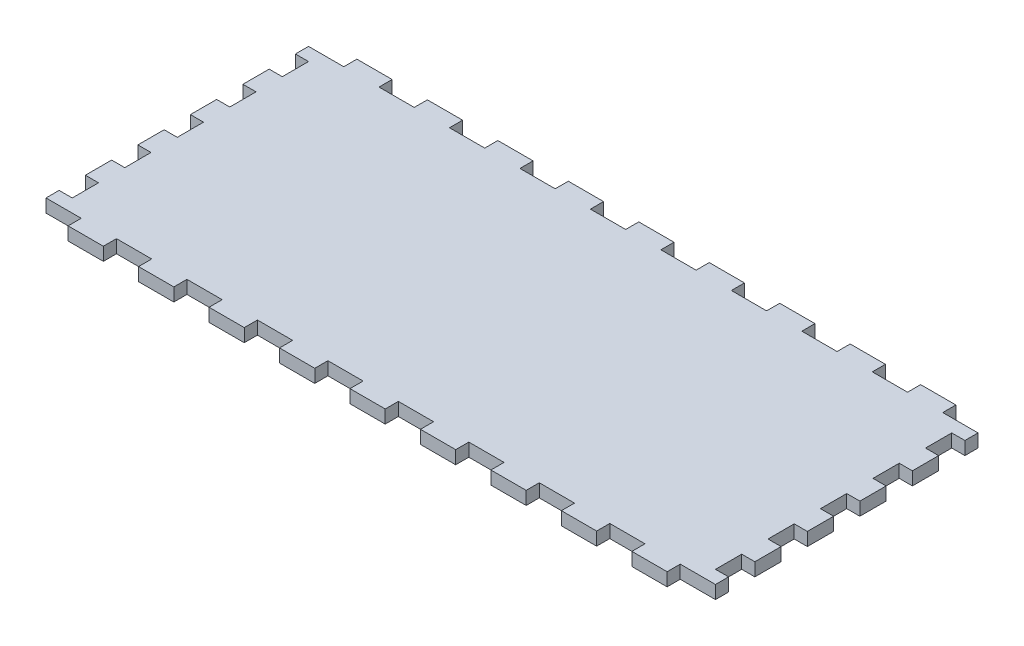
from build123d import *

# Parameters (mm, degrees)
SKETCH1_W              = 323.85
SKETCH1_H              = 139.7
BOSS_EXTRUDE1_DEPTH    = 6.35
SKETCH2_W              = 323.85
SKETCH2_H              = 139.7
SKETCH2_W_2            = 311.15
SKETCH2_H_2            = 127
BOSS_EXTRUDE2_DEPTH    = 298.45
SKETCH3_W              = 6.35
SKETCH3_H              = 16.933333333
SKETCH3_H_2            = 16.933333334
DOOR_SLOT_DEPTH        = 12.7
SKETCH4_W              = 6.35
SKETCH4_H              = 15.875
DOOR_GUIDE_HOLES_DEPTH = 6.35
LEVER_HOLES_W          = 9.652
LEVER_HOLES_H          = 6.35
LEVER_HOLES_W_2        = 6.35
CUT_EXTRUDE1_DEPTH     = 140.7
CUT_EXTRUDE2_REACH     = 325.85
SKETCH7_R              = 26.9875
CUT_EXTRUDE3_REACH     = 325.85
SKETCH8_R              = 3.175
SKETCH9_W              = 323.85
SKETCH9_H              = 298.45
CUT_EXTRUDE4_DEPTH     = 140.7
SKETCH10_W             = 10.694736842
SKETCH10_H             = 6.35
SKETCH10_W_2           = 6.35
SKETCH10_W_3           = 17.044736842
SKETCH10_W_4           = 17.044736843
SKETCH10_H_2           = 12.7
CUT_EXTRUDE6_DEPTH     = 7.35


with BuildPart() as part:
    # Sketch1 → Boss-Extrude1 (new body)
    with BuildSketch(Plane(origin=(0, 0, 0), x_dir=(1, 0, 0), z_dir=(0, 1, 0))):
        Rectangle(SKETCH1_W, SKETCH1_H)
    extrude(amount=BOSS_EXTRUDE1_DEPTH)

    # Sketch2 → Boss-Extrude2 (add)
    with BuildSketch(Plane(origin=(0, 6.35, 0), x_dir=(1, 0, 0), z_dir=(0, 1, 0))):
        Rectangle(SKETCH2_W, SKETCH2_H)
        Rectangle(SKETCH2_W_2, SKETCH2_H_2, mode=Mode.SUBTRACT)
    extrude(amount=BOSS_EXTRUDE2_DEPTH)

    # Sketch3 → Door Slot (cut)
    with BuildSketch(Plane.XY.offset(69.85)):
        with BuildLine():
            Line((-53.975, 283.21), (-53.975, 6.35))
            Line((-53.975, 6.35), (-47.371, 6.35))
            Line((-47.371, 6.35), (-47.371, 292.354))
            Line((-47.371, 292.354), (-66.929, 292.354))
            Line((-66.929, 292.354), (-66.929, 285.75))
            Line((-66.929, 285.75), (-56.515, 285.75))
            ThreePointArc((-56.515, 285.75), (-54.718948776, 285.006051224), (-53.975, 283.21))
        make_face()
        with Locations((-37.846, 80.433333334)):
            Rectangle(SKETCH3_W, SKETCH3_H)
        with Locations((-37.846, 50.8)):
            Rectangle(SKETCH3_W, SKETCH3_H_2)
        with Locations((-37.846, 21.166666667)):
            Rectangle(SKETCH3_W, SKETCH3_H)
    extrude(amount=-DOOR_SLOT_DEPTH, mode=Mode.SUBTRACT)

    # Sketch4 → Door Guide Holes (cut)
    with BuildSketch(Plane.XY.offset(-63.5)):
        with Locations((-70.104, 284.1625)):
            Rectangle(SKETCH4_W, SKETCH4_H)
        with Locations((-70.104, 255.5875)):
            Rectangle(SKETCH4_W, SKETCH4_H)
        with Locations((-70.104, 227.0125)):
            Rectangle(SKETCH4_W, SKETCH4_H)
        with Locations((-70.104, 198.4375)):
            Rectangle(SKETCH4_W, SKETCH4_H)
        with Locations((-70.104, 169.8625)):
            Rectangle(SKETCH4_W, SKETCH4_H)
        with Locations((-70.104, 141.2875)):
            Rectangle(SKETCH4_W, SKETCH4_H)
        with Locations((-70.104, 112.7125)):
            Rectangle(SKETCH4_W, SKETCH4_H)
        with Locations((-70.104, 84.1375)):
            Rectangle(SKETCH4_W, SKETCH4_H)
        with Locations((-70.104, 55.5625)):
            Rectangle(SKETCH4_W, SKETCH4_H)
        with Locations((-70.104, 26.9875)):
            Rectangle(SKETCH4_W, SKETCH4_H)
    door_guide_holes = extrude(amount=-DOOR_GUIDE_HOLES_DEPTH, mode=Mode.SUBTRACT)

    # Mirror1: Door Guide Holes across plane
    add(door_guide_holes.mirror(Plane.ZY.offset(57.15)), mode=Mode.SUBTRACT)

    # Lever Holes → Cut-Extrude1 (cut, through all)
    with BuildSketch(Plane.XY.offset(69.85)):
        with Locations((54.102, 28.575)):
            Rectangle(LEVER_HOLES_W, LEVER_HOLES_H)
        with Locations((39.3065, 15.875)):
            Rectangle(LEVER_HOLES_W_2, LEVER_HOLES_H)
        with Locations((68.8975, 15.875)):
            Rectangle(LEVER_HOLES_W_2, LEVER_HOLES_H)
    extrude(amount=-CUT_EXTRUDE1_DEPTH, mode=Mode.SUBTRACT)

    # Sketch7 → Cut-Extrude2 (cut, up to next)
    with BuildSketch(Plane(origin=(161.925, 0, 0), x_dir=(0, 0, -1), z_dir=(1, 0, 0)), mode=Mode.PRIVATE) as cut_extrude2_sk1:
        with Locations((0, 55.372)):
            Circle(SKETCH7_R)
    cut_extrude2_tool1 = extrude(cut_extrude2_sk1.sketch, amount=-CUT_EXTRUDE2_REACH, mode=Mode.PRIVATE) & part.part
    add(cut_extrude2_tool1.solids().sort_by_distance((161.925, 55.372, 0))[0], mode=Mode.SUBTRACT)
    # Sketch7 → Cut-Extrude2 (cut, up to next)
    with BuildSketch(Plane(origin=(161.925, 0, 0), x_dir=(0, 0, -1), z_dir=(1, 0, 0)), mode=Mode.PRIVATE) as cut_extrude2_sk2:
        with BuildLine():
            Line((-37.211, 89.408), (-37.211, 92.583))
            Line((-37.211, 92.583), (-34.036, 92.583))
            ThreePointArc((-34.036, 92.583), (-39.45606403, 94.82806403), (-37.211, 89.408))
        make_face()
    cut_extrude2_tool2 = extrude(cut_extrude2_sk2.sketch, amount=-CUT_EXTRUDE2_REACH, mode=Mode.PRIVATE) & part.part
    add(cut_extrude2_tool2.solids().sort_by_distance((161.925, 93.032171, 37.660171))[0], mode=Mode.SUBTRACT)
    # Sketch7 → Cut-Extrude2 (cut, up to next)
    with BuildSketch(Plane(origin=(161.925, 0, 0), x_dir=(0, 0, -1), z_dir=(1, 0, 0)), mode=Mode.PRIVATE) as cut_extrude2_sk3:
        with BuildLine():
            Line((-34.036, 92.583), (-37.211, 92.583))
            Line((-37.211, 92.583), (-37.211, 89.408))
            ThreePointArc((-37.211, 89.408), (-34.96593597, 90.33793597), (-34.036, 92.583))
        make_face()
    cut_extrude2_tool3 = extrude(cut_extrude2_sk3.sketch, amount=-CUT_EXTRUDE2_REACH, mode=Mode.PRIVATE) & part.part
    add(cut_extrude2_tool3.solids().sort_by_distance((161.925, 91.235488, 35.863488))[0], mode=Mode.SUBTRACT)
    # Sketch7 → Cut-Extrude2 (cut, up to next)
    with BuildSketch(Plane(origin=(161.925, 0, 0), x_dir=(0, 0, -1), z_dir=(1, 0, 0)), mode=Mode.PRIVATE) as cut_extrude2_sk4:
        with BuildLine():
            Line((-37.211, 89.408), (-37.211, 92.583))
            Line((-37.211, 92.583), (-34.036, 92.583))
            ThreePointArc((-34.036, 92.583), (-39.45606403, 94.82806403), (-37.211, 89.408))
        make_face()
    cut_extrude2_tool4 = extrude(cut_extrude2_sk4.sketch, amount=-CUT_EXTRUDE2_REACH, mode=Mode.PRIVATE) & part.part
    add(cut_extrude2_tool4.solids().sort_by_distance((161.925, 93.032171, 37.660171))[0], mode=Mode.SUBTRACT)
    # Sketch7 → Cut-Extrude2 (cut, up to next)
    with BuildSketch(Plane(origin=(161.925, 0, 0), x_dir=(0, 0, -1), z_dir=(1, 0, 0)), mode=Mode.PRIVATE) as cut_extrude2_sk5:
        with BuildLine():
            Line((-34.036, 92.583), (-37.211, 92.583))
            Line((-37.211, 92.583), (-37.211, 89.408))
            ThreePointArc((-37.211, 89.408), (-34.96593597, 90.33793597), (-34.036, 92.583))
        make_face()
    cut_extrude2_tool5 = extrude(cut_extrude2_sk5.sketch, amount=-CUT_EXTRUDE2_REACH, mode=Mode.PRIVATE) & part.part
    add(cut_extrude2_tool5.solids().sort_by_distance((161.925, 91.235488, 35.863488))[0], mode=Mode.SUBTRACT)
    # Sketch7 → Cut-Extrude2 (cut, up to next)
    with BuildSketch(Plane(origin=(161.925, 0, 0), x_dir=(0, 0, -1), z_dir=(1, 0, 0)), mode=Mode.PRIVATE) as cut_extrude2_sk6:
        with BuildLine():
            ThreePointArc((40.386, 92.583), (37.211, 95.758), (34.036, 92.583))
            Line((34.036, 92.583), (37.211, 92.583))
            Line((37.211, 92.583), (37.211, 89.408))
            ThreePointArc((37.211, 89.408), (39.45606403, 90.33793597), (40.386, 92.583))
        make_face()
    cut_extrude2_tool6 = extrude(cut_extrude2_sk6.sketch, amount=-CUT_EXTRUDE2_REACH, mode=Mode.PRIVATE) & part.part
    add(cut_extrude2_tool6.solids().sort_by_distance((161.925, 93.032171, -37.660171))[0], mode=Mode.SUBTRACT)
    # Sketch7 → Cut-Extrude2 (cut, up to next)
    with BuildSketch(Plane(origin=(161.925, 0, 0), x_dir=(0, 0, -1), z_dir=(1, 0, 0)), mode=Mode.PRIVATE) as cut_extrude2_sk7:
        with BuildLine():
            Line((37.211, 92.583), (34.036, 92.583))
            ThreePointArc((34.036, 92.583), (34.96593597, 90.33793597), (37.211, 89.408))
            Line((37.211, 89.408), (37.211, 92.583))
        make_face()
    cut_extrude2_tool7 = extrude(cut_extrude2_sk7.sketch, amount=-CUT_EXTRUDE2_REACH, mode=Mode.PRIVATE) & part.part
    add(cut_extrude2_tool7.solids().sort_by_distance((161.925, 91.235488, -35.863488))[0], mode=Mode.SUBTRACT)
    # Sketch7 → Cut-Extrude2 (cut, up to next)
    with BuildSketch(Plane(origin=(161.925, 0, 0), x_dir=(0, 0, -1), z_dir=(1, 0, 0)), mode=Mode.PRIVATE) as cut_extrude2_sk8:
        with BuildLine():
            ThreePointArc((40.386, 92.583), (37.211, 95.758), (34.036, 92.583))
            Line((34.036, 92.583), (37.211, 92.583))
            Line((37.211, 92.583), (37.211, 89.408))
            ThreePointArc((37.211, 89.408), (39.45606403, 90.33793597), (40.386, 92.583))
        make_face()
    cut_extrude2_tool8 = extrude(cut_extrude2_sk8.sketch, amount=-CUT_EXTRUDE2_REACH, mode=Mode.PRIVATE) & part.part
    add(cut_extrude2_tool8.solids().sort_by_distance((161.925, 93.032171, -37.660171))[0], mode=Mode.SUBTRACT)
    # Sketch7 → Cut-Extrude2 (cut, up to next)
    with BuildSketch(Plane(origin=(161.925, 0, 0), x_dir=(0, 0, -1), z_dir=(1, 0, 0)), mode=Mode.PRIVATE) as cut_extrude2_sk9:
        with BuildLine():
            Line((37.211, 92.583), (34.036, 92.583))
            ThreePointArc((34.036, 92.583), (34.96593597, 90.33793597), (37.211, 89.408))
            Line((37.211, 89.408), (37.211, 92.583))
        make_face()
    cut_extrude2_tool9 = extrude(cut_extrude2_sk9.sketch, amount=-CUT_EXTRUDE2_REACH, mode=Mode.PRIVATE) & part.part
    add(cut_extrude2_tool9.solids().sort_by_distance((161.925, 91.235488, -35.863488))[0], mode=Mode.SUBTRACT)
    # Sketch7 → Cut-Extrude2 (cut, up to next)
    with BuildSketch(Plane(origin=(161.925, 0, 0), x_dir=(0, 0, -1), z_dir=(1, 0, 0)), mode=Mode.PRIVATE) as cut_extrude2_sk10:
        with BuildLine():
            ThreePointArc((-34.036, 18.161), (-34.96593597, 20.40606403), (-37.211, 21.336))
            Line((-37.211, 21.336), (-37.211, 18.161))
            Line((-37.211, 18.161), (-34.036, 18.161))
        make_face()
    cut_extrude2_tool10 = extrude(cut_extrude2_sk10.sketch, amount=-CUT_EXTRUDE2_REACH, mode=Mode.PRIVATE) & part.part
    add(cut_extrude2_tool10.solids().sort_by_distance((161.925, 19.508512, 35.863488))[0], mode=Mode.SUBTRACT)
    # Sketch7 → Cut-Extrude2 (cut, up to next)
    with BuildSketch(Plane(origin=(161.925, 0, 0), x_dir=(0, 0, -1), z_dir=(1, 0, 0)), mode=Mode.PRIVATE) as cut_extrude2_sk11:
        with BuildLine():
            Line((-37.211, 18.161), (-37.211, 21.336))
            ThreePointArc((-37.211, 21.336), (-39.45606403, 15.91593597), (-34.036, 18.161))
            Line((-34.036, 18.161), (-37.211, 18.161))
        make_face()
    cut_extrude2_tool11 = extrude(cut_extrude2_sk11.sketch, amount=-CUT_EXTRUDE2_REACH, mode=Mode.PRIVATE) & part.part
    add(cut_extrude2_tool11.solids().sort_by_distance((161.925, 17.711829, 37.660171))[0], mode=Mode.SUBTRACT)
    # Sketch7 → Cut-Extrude2 (cut, up to next)
    with BuildSketch(Plane(origin=(161.925, 0, 0), x_dir=(0, 0, -1), z_dir=(1, 0, 0)), mode=Mode.PRIVATE) as cut_extrude2_sk12:
        with BuildLine():
            ThreePointArc((-34.036, 18.161), (-34.96593597, 20.40606403), (-37.211, 21.336))
            Line((-37.211, 21.336), (-37.211, 18.161))
            Line((-37.211, 18.161), (-34.036, 18.161))
        make_face()
    cut_extrude2_tool12 = extrude(cut_extrude2_sk12.sketch, amount=-CUT_EXTRUDE2_REACH, mode=Mode.PRIVATE) & part.part
    add(cut_extrude2_tool12.solids().sort_by_distance((161.925, 19.508512, 35.863488))[0], mode=Mode.SUBTRACT)
    # Sketch7 → Cut-Extrude2 (cut, up to next)
    with BuildSketch(Plane(origin=(161.925, 0, 0), x_dir=(0, 0, -1), z_dir=(1, 0, 0)), mode=Mode.PRIVATE) as cut_extrude2_sk13:
        with BuildLine():
            Line((-37.211, 18.161), (-37.211, 21.336))
            ThreePointArc((-37.211, 21.336), (-39.45606403, 15.91593597), (-34.036, 18.161))
            Line((-34.036, 18.161), (-37.211, 18.161))
        make_face()
    cut_extrude2_tool13 = extrude(cut_extrude2_sk13.sketch, amount=-CUT_EXTRUDE2_REACH, mode=Mode.PRIVATE) & part.part
    add(cut_extrude2_tool13.solids().sort_by_distance((161.925, 17.711829, 37.660171))[0], mode=Mode.SUBTRACT)
    # Sketch7 → Cut-Extrude2 (cut, up to next)
    with BuildSketch(Plane(origin=(161.925, 0, 0), x_dir=(0, 0, -1), z_dir=(1, 0, 0)), mode=Mode.PRIVATE) as cut_extrude2_sk14:
        with BuildLine():
            ThreePointArc((40.386, 18.161), (39.45606403, 20.40606403), (37.211, 21.336))
            Line((37.211, 21.336), (37.211, 18.161))
            Line((37.211, 18.161), (34.036, 18.161))
            ThreePointArc((34.036, 18.161), (37.211, 14.986), (40.386, 18.161))
        make_face()
    cut_extrude2_tool14 = extrude(cut_extrude2_sk14.sketch, amount=-CUT_EXTRUDE2_REACH, mode=Mode.PRIVATE) & part.part
    add(cut_extrude2_tool14.solids().sort_by_distance((161.925, 17.711829, -37.660171))[0], mode=Mode.SUBTRACT)
    # Sketch7 → Cut-Extrude2 (cut, up to next)
    with BuildSketch(Plane(origin=(161.925, 0, 0), x_dir=(0, 0, -1), z_dir=(1, 0, 0)), mode=Mode.PRIVATE) as cut_extrude2_sk15:
        with BuildLine():
            Line((37.211, 18.161), (37.211, 21.336))
            ThreePointArc((37.211, 21.336), (34.96593597, 20.40606403), (34.036, 18.161))
            Line((34.036, 18.161), (37.211, 18.161))
        make_face()
    cut_extrude2_tool15 = extrude(cut_extrude2_sk15.sketch, amount=-CUT_EXTRUDE2_REACH, mode=Mode.PRIVATE) & part.part
    add(cut_extrude2_tool15.solids().sort_by_distance((161.925, 19.508512, -35.863488))[0], mode=Mode.SUBTRACT)
    # Sketch7 → Cut-Extrude2 (cut, up to next)
    with BuildSketch(Plane(origin=(161.925, 0, 0), x_dir=(0, 0, -1), z_dir=(1, 0, 0)), mode=Mode.PRIVATE) as cut_extrude2_sk16:
        with BuildLine():
            ThreePointArc((40.386, 18.161), (39.45606403, 20.40606403), (37.211, 21.336))
            Line((37.211, 21.336), (37.211, 18.161))
            Line((37.211, 18.161), (34.036, 18.161))
            ThreePointArc((34.036, 18.161), (37.211, 14.986), (40.386, 18.161))
        make_face()
    cut_extrude2_tool16 = extrude(cut_extrude2_sk16.sketch, amount=-CUT_EXTRUDE2_REACH, mode=Mode.PRIVATE) & part.part
    add(cut_extrude2_tool16.solids().sort_by_distance((161.925, 17.711829, -37.660171))[0], mode=Mode.SUBTRACT)
    # Sketch7 → Cut-Extrude2 (cut, up to next)
    with BuildSketch(Plane(origin=(161.925, 0, 0), x_dir=(0, 0, -1), z_dir=(1, 0, 0)), mode=Mode.PRIVATE) as cut_extrude2_sk17:
        with BuildLine():
            Line((37.211, 18.161), (37.211, 21.336))
            ThreePointArc((37.211, 21.336), (34.96593597, 20.40606403), (34.036, 18.161))
            Line((34.036, 18.161), (37.211, 18.161))
        make_face()
    cut_extrude2_tool17 = extrude(cut_extrude2_sk17.sketch, amount=-CUT_EXTRUDE2_REACH, mode=Mode.PRIVATE) & part.part
    add(cut_extrude2_tool17.solids().sort_by_distance((161.925, 19.508512, -35.863488))[0], mode=Mode.SUBTRACT)

    # Sketch8 → Cut-Extrude3 (cut, up to next)
    with BuildSketch(Plane.ZY.offset(161.925), mode=Mode.PRIVATE) as cut_extrude3_sk1:
        with Locations((0, 19.05)):
            Circle(SKETCH8_R)
    cut_extrude3_tool1 = extrude(cut_extrude3_sk1.sketch, amount=-CUT_EXTRUDE3_REACH, mode=Mode.PRIVATE) & part.part
    add(cut_extrude3_tool1.solids().sort_by_distance((-161.925, 19.05, 0))[0], mode=Mode.SUBTRACT)

    # Sketch9 → Cut-Extrude4 (cut, through all)
    with BuildSketch(Plane(origin=(0, 0, -69.85), x_dir=(-1, 0, 0), z_dir=(0, 0, -1))):
        with Locations((0, 155.575)):
            Rectangle(SKETCH9_W, SKETCH9_H)
    extrude(amount=-CUT_EXTRUDE4_DEPTH, mode=Mode.SUBTRACT)

    # Sketch10 → Cut-Extrude6 (cut, through all)
    with BuildSketch(Plane.XZ):
        with Locations((-150.227631579, 66.675)):
            Rectangle(SKETCH10_W, SKETCH10_H)
        with Locations((-158.75, 66.675)):
            Rectangle(SKETCH10_W_2, SKETCH10_H)
        with Locations((-119.313157895, 66.675)):
            Rectangle(SKETCH10_W_3, SKETCH10_H)
        with Locations((-85.223684211, 66.675)):
            Rectangle(SKETCH10_W_4, SKETCH10_H)
        with Locations((-51.134210526, 66.675)):
            Rectangle(SKETCH10_W_3, SKETCH10_H)
        with Locations((-17.044736842, 66.675)):
            Rectangle(SKETCH10_W_3, SKETCH10_H)
        with Locations((17.044736842, 66.675)):
            Rectangle(SKETCH10_W_3, SKETCH10_H)
        with Locations((51.134210526, 66.675)):
            Rectangle(SKETCH10_W_3, SKETCH10_H)
        with Locations((85.223684211, 66.675)):
            Rectangle(SKETCH10_W_4, SKETCH10_H)
        with Locations((119.313157895, 66.675)):
            Rectangle(SKETCH10_W_3, SKETCH10_H)
        with Locations((150.227631579, 66.675)):
            Rectangle(SKETCH10_W, SKETCH10_H)
        with Locations((158.75, 66.675)):
            Rectangle(SKETCH10_W_2, SKETCH10_H)
        with Locations((158.75, 50.8)):
            Rectangle(SKETCH10_W_2, SKETCH10_H_2)
        with Locations((158.75, 25.4)):
            Rectangle(SKETCH10_W_2, SKETCH10_H_2)
        with Locations((158.75, 0)):
            Rectangle(SKETCH10_W_2, SKETCH10_H_2)
        with Locations((158.75, -25.4)):
            Rectangle(SKETCH10_W_2, SKETCH10_H_2)
        with Locations((158.75, -50.8)):
            Rectangle(SKETCH10_W_2, SKETCH10_H_2)
        with Locations((158.75, -66.675)):
            Rectangle(SKETCH10_W_2, SKETCH10_H)
        with Locations((150.227631579, -66.675)):
            Rectangle(SKETCH10_W, SKETCH10_H)
        with Locations((119.313157895, -66.675)):
            Rectangle(SKETCH10_W_3, SKETCH10_H)
        with Locations((85.223684211, -66.675)):
            Rectangle(SKETCH10_W_4, SKETCH10_H)
        with Locations((51.134210526, -66.675)):
            Rectangle(SKETCH10_W_3, SKETCH10_H)
        with Locations((17.044736842, -66.675)):
            Rectangle(SKETCH10_W_3, SKETCH10_H)
        with Locations((-17.044736842, -66.675)):
            Rectangle(SKETCH10_W_3, SKETCH10_H)
        with Locations((-51.134210526, -66.675)):
            Rectangle(SKETCH10_W_3, SKETCH10_H)
        with Locations((-85.223684211, -66.675)):
            Rectangle(SKETCH10_W_4, SKETCH10_H)
        with Locations((-119.313157895, -66.675)):
            Rectangle(SKETCH10_W_3, SKETCH10_H)
        with Locations((-158.75, -66.675)):
            Rectangle(SKETCH10_W_2, SKETCH10_H)
        with Locations((-150.227631579, -66.675)):
            Rectangle(SKETCH10_W, SKETCH10_H)
        with Locations((-158.75, -50.8)):
            Rectangle(SKETCH10_W_2, SKETCH10_H_2)
        with Locations((-158.75, -25.4)):
            Rectangle(SKETCH10_W_2, SKETCH10_H_2)
        with Locations((-158.75, 0)):
            Rectangle(SKETCH10_W_2, SKETCH10_H_2)
        with Locations((-158.75, 25.4)):
            Rectangle(SKETCH10_W_2, SKETCH10_H_2)
        with Locations((-158.75, 50.8)):
            Rectangle(SKETCH10_W_2, SKETCH10_H_2)
    extrude(amount=-CUT_EXTRUDE6_DEPTH, mode=Mode.SUBTRACT)


solid = part.part
